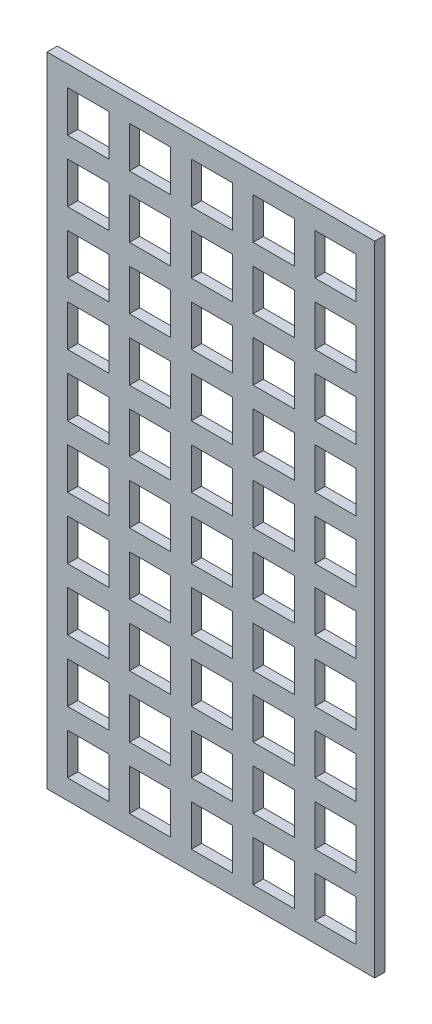
from build123d import *

# Parameters (mm, degrees)
SKETCH1_W           = 79.5
SKETCH1_H           = 154.8
SKETCH1_W_2         = 10
SKETCH1_H_2         = 10
BOSS_EXTRUDE1_DEPTH = 2.5


with BuildPart() as part:
    # Sketch1 → Boss-Extrude1 (new body)
    with BuildSketch(Plane.XY):
        with Locations((39.75, -77.4)):
            Rectangle(SKETCH1_W, SKETCH1_H)
        with Locations((10, -10)):
            Rectangle(SKETCH1_W_2, SKETCH1_H_2, mode=Mode.SUBTRACT)
        with Locations((25, -10)):
            Rectangle(SKETCH1_W_2, SKETCH1_H_2, mode=Mode.SUBTRACT)
        with Locations((40, -10)):
            Rectangle(SKETCH1_W_2, SKETCH1_H_2, mode=Mode.SUBTRACT)
        with Locations((55, -10)):
            Rectangle(SKETCH1_W_2, SKETCH1_H_2, mode=Mode.SUBTRACT)
        with Locations((70, -10)):
            Rectangle(SKETCH1_W_2, SKETCH1_H_2, mode=Mode.SUBTRACT)
        with Locations((25, -25)):
            Rectangle(SKETCH1_W_2, SKETCH1_H_2, mode=Mode.SUBTRACT)
        with Locations((40, -25)):
            Rectangle(SKETCH1_W_2, SKETCH1_H_2, mode=Mode.SUBTRACT)
        with Locations((55, -25)):
            Rectangle(SKETCH1_W_2, SKETCH1_H_2, mode=Mode.SUBTRACT)
        with Locations((70, -25)):
            Rectangle(SKETCH1_W_2, SKETCH1_H_2, mode=Mode.SUBTRACT)
        with Locations((25, -40)):
            Rectangle(SKETCH1_W_2, SKETCH1_H_2, mode=Mode.SUBTRACT)
        with Locations((40, -40)):
            Rectangle(SKETCH1_W_2, SKETCH1_H_2, mode=Mode.SUBTRACT)
        with Locations((55, -40)):
            Rectangle(SKETCH1_W_2, SKETCH1_H_2, mode=Mode.SUBTRACT)
        with Locations((70, -40)):
            Rectangle(SKETCH1_W_2, SKETCH1_H_2, mode=Mode.SUBTRACT)
        with Locations((25, -55)):
            Rectangle(SKETCH1_W_2, SKETCH1_H_2, mode=Mode.SUBTRACT)
        with Locations((40, -55)):
            Rectangle(SKETCH1_W_2, SKETCH1_H_2, mode=Mode.SUBTRACT)
        with Locations((55, -55)):
            Rectangle(SKETCH1_W_2, SKETCH1_H_2, mode=Mode.SUBTRACT)
        with Locations((70, -55)):
            Rectangle(SKETCH1_W_2, SKETCH1_H_2, mode=Mode.SUBTRACT)
        with Locations((25, -70)):
            Rectangle(SKETCH1_W_2, SKETCH1_H_2, mode=Mode.SUBTRACT)
        with Locations((40, -70)):
            Rectangle(SKETCH1_W_2, SKETCH1_H_2, mode=Mode.SUBTRACT)
        with Locations((55, -70)):
            Rectangle(SKETCH1_W_2, SKETCH1_H_2, mode=Mode.SUBTRACT)
        with Locations((70, -70)):
            Rectangle(SKETCH1_W_2, SKETCH1_H_2, mode=Mode.SUBTRACT)
        with Locations((25, -85)):
            Rectangle(SKETCH1_W_2, SKETCH1_H_2, mode=Mode.SUBTRACT)
        with Locations((40, -85)):
            Rectangle(SKETCH1_W_2, SKETCH1_H_2, mode=Mode.SUBTRACT)
        with Locations((55, -85)):
            Rectangle(SKETCH1_W_2, SKETCH1_H_2, mode=Mode.SUBTRACT)
        with Locations((70, -85)):
            Rectangle(SKETCH1_W_2, SKETCH1_H_2, mode=Mode.SUBTRACT)
        with Locations((25, -100)):
            Rectangle(SKETCH1_W_2, SKETCH1_H_2, mode=Mode.SUBTRACT)
        with Locations((40, -100)):
            Rectangle(SKETCH1_W_2, SKETCH1_H_2, mode=Mode.SUBTRACT)
        with Locations((55, -100)):
            Rectangle(SKETCH1_W_2, SKETCH1_H_2, mode=Mode.SUBTRACT)
        with Locations((70, -100)):
            Rectangle(SKETCH1_W_2, SKETCH1_H_2, mode=Mode.SUBTRACT)
        with Locations((25, -115)):
            Rectangle(SKETCH1_W_2, SKETCH1_H_2, mode=Mode.SUBTRACT)
        with Locations((40, -115)):
            Rectangle(SKETCH1_W_2, SKETCH1_H_2, mode=Mode.SUBTRACT)
        with Locations((55, -115)):
            Rectangle(SKETCH1_W_2, SKETCH1_H_2, mode=Mode.SUBTRACT)
        with Locations((70, -115)):
            Rectangle(SKETCH1_W_2, SKETCH1_H_2, mode=Mode.SUBTRACT)
        with Locations((25, -130)):
            Rectangle(SKETCH1_W_2, SKETCH1_H_2, mode=Mode.SUBTRACT)
        with Locations((40, -130)):
            Rectangle(SKETCH1_W_2, SKETCH1_H_2, mode=Mode.SUBTRACT)
        with Locations((55, -130)):
            Rectangle(SKETCH1_W_2, SKETCH1_H_2, mode=Mode.SUBTRACT)
        with Locations((70, -130)):
            Rectangle(SKETCH1_W_2, SKETCH1_H_2, mode=Mode.SUBTRACT)
        with Locations((25, -145)):
            Rectangle(SKETCH1_W_2, SKETCH1_H_2, mode=Mode.SUBTRACT)
        with Locations((40, -145)):
            Rectangle(SKETCH1_W_2, SKETCH1_H_2, mode=Mode.SUBTRACT)
        with Locations((55, -145)):
            Rectangle(SKETCH1_W_2, SKETCH1_H_2, mode=Mode.SUBTRACT)
        with Locations((70, -145)):
            Rectangle(SKETCH1_W_2, SKETCH1_H_2, mode=Mode.SUBTRACT)
        with Locations((10, -25)):
            Rectangle(SKETCH1_W_2, SKETCH1_H_2, mode=Mode.SUBTRACT)
        with Locations((10, -40)):
            Rectangle(SKETCH1_W_2, SKETCH1_H_2, mode=Mode.SUBTRACT)
        with Locations((10, -55)):
            Rectangle(SKETCH1_W_2, SKETCH1_H_2, mode=Mode.SUBTRACT)
        with Locations((10, -70)):
            Rectangle(SKETCH1_W_2, SKETCH1_H_2, mode=Mode.SUBTRACT)
        with Locations((10, -85)):
            Rectangle(SKETCH1_W_2, SKETCH1_H_2, mode=Mode.SUBTRACT)
        with Locations((10, -100)):
            Rectangle(SKETCH1_W_2, SKETCH1_H_2, mode=Mode.SUBTRACT)
        with Locations((10, -115)):
            Rectangle(SKETCH1_W_2, SKETCH1_H_2, mode=Mode.SUBTRACT)
        with Locations((10, -130)):
            Rectangle(SKETCH1_W_2, SKETCH1_H_2, mode=Mode.SUBTRACT)
        with Locations((10, -145)):
            Rectangle(SKETCH1_W_2, SKETCH1_H_2, mode=Mode.SUBTRACT)
    extrude(amount=BOSS_EXTRUDE1_DEPTH)


solid = part.part
